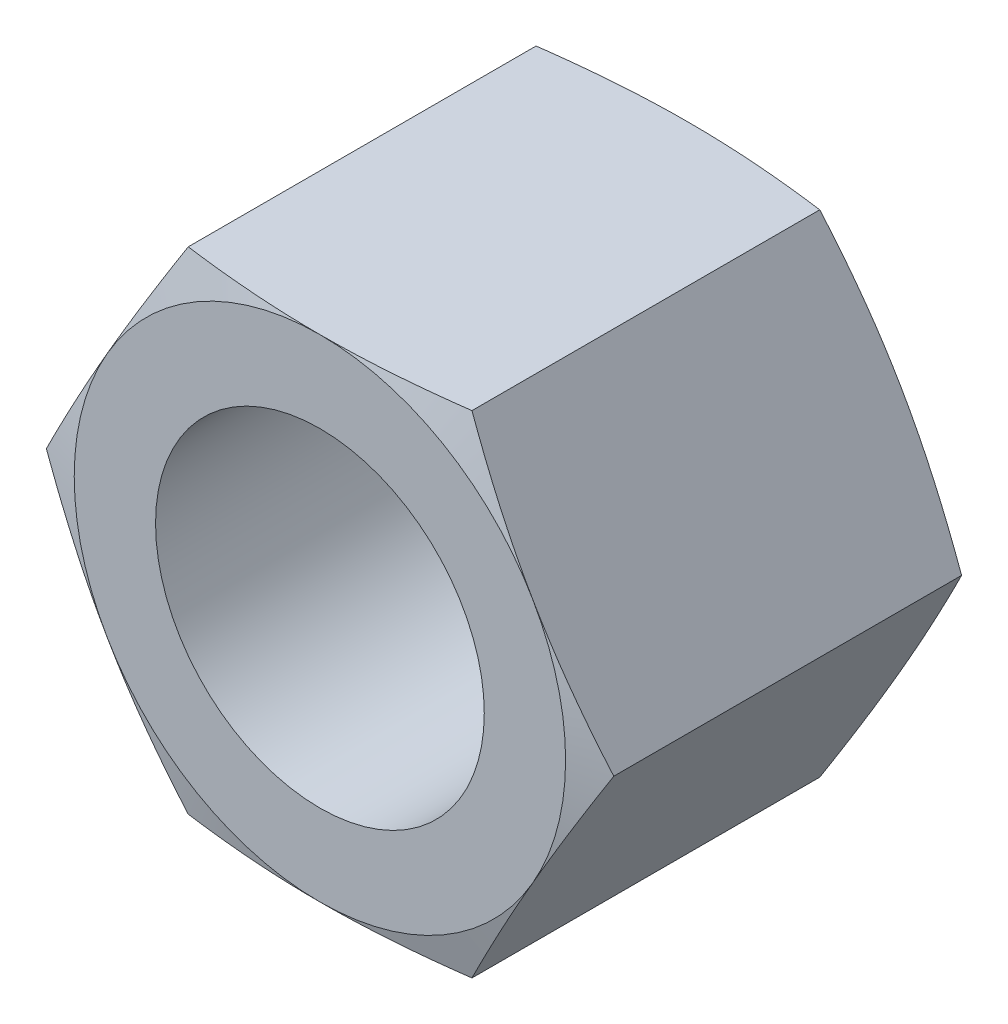
from build123d import *

# Parameters (mm, degrees)
SKETCH_1_R          = 2.5
EXTRUDE_587_DEPTH   = 5.6
SKETCH_2_OUTSIDE_W  = 296.81
SKETCH_2_OUTSIDE_H  = 295.654
SKETCH_2_OUTSIDE_R  = 3.736899617
CUT_EXTRUDE_1_DEPTH = 38
CUT_EXTRUDE_1_TAPER = 75
SKETCH_3_OUTSIDE_W  = 296.81
SKETCH_3_OUTSIDE_H  = 295.654
SKETCH_3_OUTSIDE_R  = 3.736899617
CUT_EXTRUDE_2_DEPTH = 38
CUT_EXTRUDE_2_TAPER = 75


with BuildPart() as part:
    # 草图1 → Extrude 587 (new body)
    with BuildSketch(Plane.XY):
        Polygon((2.1575, 3.736899617), (-2.1575, 3.736899617), (-4.315, 0), (-2.1575, -3.736899617), (2.1575, -3.736899617), (4.315, 0), align=None)
        Circle(SKETCH_1_R, mode=Mode.SUBTRACT)
    extrude(amount=EXTRUDE_587_DEPTH)

    # 草图2 outside → 切除-拉伸1 (cut)
    with BuildSketch(Plane(origin=(0, 0, 0), x_dir=(-1, 0, 0), z_dir=(0, 0, -1))):
        Rectangle(SKETCH_2_OUTSIDE_W, SKETCH_2_OUTSIDE_H)
        Circle(SKETCH_2_OUTSIDE_R, mode=Mode.SUBTRACT)
    extrude(amount=-CUT_EXTRUDE_1_DEPTH, taper=CUT_EXTRUDE_1_TAPER, mode=Mode.SUBTRACT)

    # 草图3 outside → 切除-拉伸2 (cut)
    with BuildSketch(Plane.XY.offset(5.6)):
        Rectangle(SKETCH_3_OUTSIDE_W, SKETCH_3_OUTSIDE_H)
        Circle(SKETCH_3_OUTSIDE_R, mode=Mode.SUBTRACT)
    extrude(amount=-CUT_EXTRUDE_2_DEPTH, taper=CUT_EXTRUDE_2_TAPER, mode=Mode.SUBTRACT)


solid = part.part
